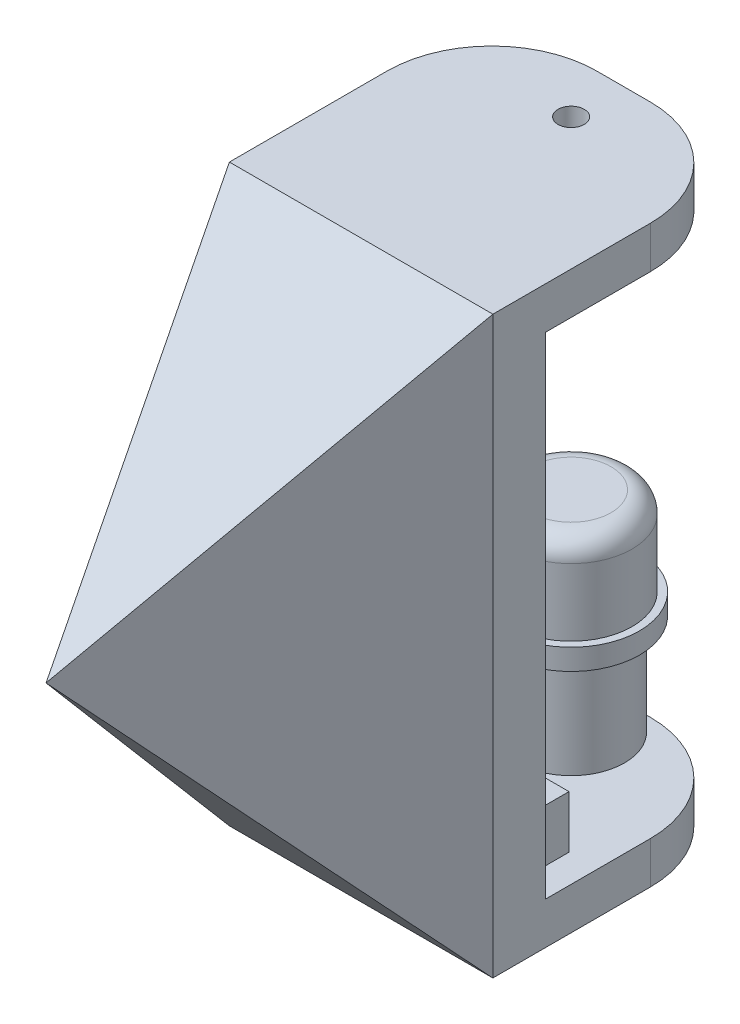
from build123d import *

# Parameters (mm, degrees)
SKETCH4_W                = 12.46
SKETCH4_H                = 17.25
BOSS_EXTRUDE3_DEPTH      = 6
SKETCH8_R                = 12.546781182
SKETCH8_R_2              = 11.15
BOSS_EXTRUDE6_DEPTH      = 7.3
BOSS_EXTRUDE6_DEPTH_BACK = 17.25
BOSS_EXTRUDE4_DEPTH      = 17.25
SKETCH6_R                = 0.5
CUT_EXTRUDE1_DEPTH       = 15
CHAMFER1_SIZE            = 0.5
CHAMFER1_SIZE2           = 0.866025404
SKETCH10_W               = 12.46
SKETCH10_H               = 23.7
CUT_EXTRUDE3_DEPTH       = 17.25
CUT_EXTRUDE4_REACH       = 38.097
SKETCH11_W               = 5
SKETCH11_H               = 3
BOSS_EXTRUDE7_DEPTH      = 7.3
BOSS_EXTRUDE9_DEPTH      = 10
SKETCH20_R               = 11.15
SKETCH20_R_2             = 7.15
BOSS_EXTRUDE11_DEPTH     = 7.3
SKETCH21_R               = 10.15
SKETCH21_R_2             = 7.15
CUT_EXTRUDE7_DEPTH       = 1.3
BOSS_EXTRUDE10_DEPTH     = 25.093562
SKETCH18_W               = 20
SKETCH18_H               = 12.438292938
CUT_EXTRUDE5_DEPTH       = 2
SKETCH19_R               = 1.25
CUT_EXTRUDE6_DEPTH       = 53.75
CUT_EXTRUDE6_DEPTH_BACK  = 3
FILLET1_R                = 10
SKETCH22_R               = 5.8
BOSS_EXTRUDE12_DEPTH     = 20
FILLET2_R                = 2
SKETCH23_R               = 5.930854157
SKETCH23_R_2             = 5.08
CUT_EXTRUDE8_DEPTH       = 11.6
SKETCH24_R               = 6.5
BOSS_EXTRUDE13_DEPTH     = 2
SKETCH25_R               = 1.25
BOSS_EXTRUDE14_DEPTH     = 2
SKETCH26_W               = 5
SKETCH26_H               = 3
BOSS_EXTRUDE15_DEPTH     = 5
SKETCH27_W               = 27.233314403
SKETCH27_H               = 38.605371191
CUT_EXTRUDE9_DEPTH       = 51.35
BOSS_EXTRUDE16_DEPTH     = 54.75
CUT_EXTRUDE10_DEPTH      = 13.546781182
CUT_EXTRUDE10_DEPTH_BACK = 13.546781182
CUT_EXTRUDE11_DEPTH      = 36


with BuildPart() as part:
    # Sketch4 → Boss-Extrude3 (new body)
    with BuildSketch(Plane.XY):
        with Locations((0, -1.35)):
            Rectangle(SKETCH4_W, SKETCH4_H)
    extrude(amount=BOSS_EXTRUDE3_DEPTH)



with BuildPart() as body_2:
    # Sketch8 → Boss-Extrude6 (new body, two sides)
    with BuildSketch(Plane(origin=(0, -9.975, 0), x_dir=(-1, 0, 0), z_dir=(0, -1, 0))) as boss_extrude6_sk:
        with Locations((0, -23.55)):
            Circle(SKETCH8_R)
        with Locations((0, -23.55)):
            Circle(SKETCH8_R_2, mode=Mode.SUBTRACT)
    extrude(amount=BOSS_EXTRUDE6_DEPTH)
    extrude(boss_extrude6_sk.sketch, amount=-BOSS_EXTRUDE6_DEPTH_BACK)


with BuildPart() as part_1:
    add(part.part)

    add(body_2.part)  # Boss-Extrude4 merges body 2
    # Sketch5 → Boss-Extrude4 (add)
    with BuildSketch(Plane(origin=(0, 7.275, 0), x_dir=(1, 0, 0), z_dir=(0, 1, 0))):
        with BuildLine():
            Line((12.546781182, -23.55), (12.546781182, 0))
            Line((12.546781182, 0), (6.23, 0))
            Line((6.23, 0), (6.23, -29.7))
            Line((6.23, -29.7), (-6.23, -29.7))
            Line((-6.23, -29.7), (-6.23, 0))
            Line((-6.23, 0), (-12.546781182, 0))
            Line((-12.546781182, 0), (-12.546781182, -23.55))
            ThreePointArc((-12.546781182, -23.55), (0, -36.096781182), (12.546781182, -23.55))
        make_face()
    extrude(amount=-BOSS_EXTRUDE4_DEPTH)

    # Sketch6 → Cut-Extrude1 (cut)
    with BuildSketch(Plane(origin=(0, 7.275, 0), x_dir=(1, 0, 0), z_dir=(0, 1, 0))):
        with Locations((0, -3.6)):
            Circle(SKETCH6_R)
        with Locations((0, -32.1)):
            Circle(SKETCH6_R)
    extrude(amount=-CUT_EXTRUDE1_DEPTH, mode=Mode.SUBTRACT)

    # Chamfer1
    chamfer1_edges = [part_1.edges().sort_by_distance(p)[0] for p in [
        (-0.5, 7.275, 3.6),
        (-0.5, 7.275, 32.1),
    ]]
    chamfer1_side = [part_1.faces().sort_by_distance(p)[0] for p in [
        (0, 7.275, 35.657160381),
    ]]
    chamfer(chamfer1_edges, length=CHAMFER1_SIZE, length2=CHAMFER1_SIZE2, reference=chamfer1_side[0])

    # Sketch10 → Cut-Extrude3 (cut)
    with BuildSketch(Plane(origin=(0, 7.275, 0), x_dir=(1, 0, 0), z_dir=(0, 1, 0))):
        with Locations((0, -17.85)):
            Rectangle(SKETCH10_W, SKETCH10_H)
    extrude(amount=-CUT_EXTRUDE3_DEPTH, mode=Mode.SUBTRACT)

    # Sketch11 → Cut-Extrude4 (cut, up to next)
    with BuildSketch(Plane.XY.offset(36.096781182), mode=Mode.PRIVATE) as cut_extrude4_sk1:
        with Locations((0, -8.475)):
            Rectangle(SKETCH11_W, SKETCH11_H)
    cut_extrude4_tool1 = extrude(cut_extrude4_sk1.sketch, amount=-CUT_EXTRUDE4_REACH, mode=Mode.PRIVATE) & part_1.part
    add(cut_extrude4_tool1.solids().sort_by_distance((0, -8.475, 36.096781))[0], mode=Mode.SUBTRACT)

    # Sketch13 → Boss-Extrude7 (add)
    with BuildSketch(Plane.XZ.offset(17.275)):
        with BuildLine():
            Line((-12.546781182, 23.55), (-12.546781182, 0))
            Line((-12.546781182, 0), (12.546781182, 0))
            Line((12.546781182, 0), (12.546781182, 23.55))
            ThreePointArc((12.546781182, 23.55), (0, 11.003218818), (-12.546781182, 23.55))
        make_face()
    extrude(amount=-BOSS_EXTRUDE7_DEPTH)

    # Sketch15 → Boss-Extrude9 (add)
    with BuildSketch(Plane(origin=(0, 7.275, 0), x_dir=(1, 0, 0), z_dir=(0, 1, 0))):
        with BuildLine():
            Line((-12.546781182, 0), (12.546781182, 0))
            Line((12.546781182, 0), (12.546781182, -23.55))
            ThreePointArc((12.546781182, -23.55), (0, -36.096781182), (-12.546781182, -23.55))
            Line((-12.546781182, -23.55), (-12.546781182, 0))
        make_face()
        with BuildLine():
            Line((-6.23, -0.8), (6.23, -0.8))
            Line((6.23, -0.8), (6.23, -33.5))
            ThreePointArc((6.23, -33.5), (5.937106781, -34.207106781), (5.23, -34.5))
            Line((5.23, -34.5), (-5.23, -34.5))
            ThreePointArc((-5.23, -34.5), (-5.937106781, -34.207106781), (-6.23, -33.5))
            Line((-6.23, -33.5), (-6.23, -0.8))
        make_face(mode=Mode.SUBTRACT)
    extrude(amount=BOSS_EXTRUDE9_DEPTH)

    # Sketch20 → Boss-Extrude11 (add)
    with BuildSketch(Plane.XZ.offset(17.275)):
        with Locations((0, 23.55)):
            Circle(SKETCH20_R)
        with Locations((0, 23.55)):
            Circle(SKETCH20_R_2, mode=Mode.SUBTRACT)
    extrude(amount=-BOSS_EXTRUDE11_DEPTH)

    # Sketch21 → Cut-Extrude7 (cut)
    with BuildSketch(Plane.XZ.offset(17.275)):
        with Locations((0, 23.55)):
            Circle(SKETCH21_R)
        with Locations((0, 23.55)):
            Circle(SKETCH21_R_2, mode=Mode.SUBTRACT)
    extrude(amount=-CUT_EXTRUDE7_DEPTH, mode=Mode.SUBTRACT)

    # Sketch17 → Boss-Extrude10 (add)
    with BuildSketch(Plane(origin=(12.546781182, 4.728218818, 0), x_dir=(0, 1, 0), z_dir=(-1, 0, 0))):
        Polygon((16.946781182, 25), (16.946781182, 0), (-37.803218818, 0), (-37.803218818, 25), (-33.803218818, 25), (-33.803218818, 5), (12.946781182, 5), (12.946781182, 25), align=None)
    extrude(amount=BOSS_EXTRUDE10_DEPTH)

    # Sketch18 → Cut-Extrude5 (cut)
    with BuildSketch(Plane(origin=(0, 17.675, 0), x_dir=(0, 0, 1), z_dir=(0, -1, 0))):
        with Locations((-15, 0)):
            Rectangle(SKETCH18_W, SKETCH18_H)
    extrude(amount=-CUT_EXTRUDE5_DEPTH, mode=Mode.SUBTRACT)

    # Sketch19 → Cut-Extrude6 (cut, two sides)
    with BuildSketch(Plane(origin=(0, 19.675, 0), x_dir=(0, 0, 1), z_dir=(0, -1, 0))) as cut_extrude6_sk:
        with Locations((-20, 0)):
            Circle(SKETCH19_R)
    extrude(amount=CUT_EXTRUDE6_DEPTH, mode=Mode.SUBTRACT)
    extrude(cut_extrude6_sk.sketch, amount=-CUT_EXTRUDE6_DEPTH_BACK, mode=Mode.SUBTRACT)

    # Fillet1
    fillet1_edges = [part_1.edges().sort_by_distance(p)[0] for p in [
        (-12.546780818, 19.675, -25),
        (12.546781182, 19.675, -25),
        (12.546781182, -31.075, -25),
        (-12.546780818, -31.075, -25),
    ]]
    fillet(fillet1_edges, radius=FILLET1_R)

    # Sketch22 → Boss-Extrude12 (add)
    with BuildSketch(Plane(origin=(0, -29.075, 0), x_dir=(0, 0, -1), z_dir=(0, 1, 0))):
        with Locations((20, 0)):
            Circle(SKETCH22_R)
    extrude(amount=BOSS_EXTRUDE12_DEPTH)

    # Fillet2
    fillet2_edges = [part_1.edges().sort_by_distance(p)[0] for p in [
        (0, -9.075, -14.2),
    ]]
    fillet(fillet2_edges, radius=FILLET2_R)

    # Sketch23 → Cut-Extrude8 (cut)
    with BuildSketch(Plane(origin=(0, -29.075, 0), x_dir=(0, 0, -1), z_dir=(0, 1, 0))):
        with Locations((20, 0)):
            Circle(SKETCH23_R)
        with Locations((20, 0)):
            Circle(SKETCH23_R_2, mode=Mode.SUBTRACT)
    extrude(amount=CUT_EXTRUDE8_DEPTH, mode=Mode.SUBTRACT)

    # Sketch24 → Boss-Extrude13 (add)
    with BuildSketch(Plane(origin=(0, -17.475, 0), x_dir=(0, 0, 1), z_dir=(0, -1, 0))):
        with Locations((-20, 0)):
            Circle(SKETCH24_R)
    extrude(amount=BOSS_EXTRUDE13_DEPTH)

    # Sketch25 → Boss-Extrude14 (add)
    with BuildSketch(Plane(origin=(0, -33.075, 0), x_dir=(0, 0, 1), z_dir=(0, -1, 0))):
        with Locations((-20, 0)):
            Circle(SKETCH25_R)
    extrude(amount=-BOSS_EXTRUDE14_DEPTH)

    # Sketch26 → Boss-Extrude15 (add)
    with BuildSketch(Plane(origin=(0, -29.075, 0), x_dir=(0, 0, -1), z_dir=(0, 1, 0))):
        with Locations((7.5, -8.296781182)):
            Rectangle(SKETCH26_W, SKETCH26_H)
        with Locations((7.5, -3.780781182)):
            Rectangle(SKETCH26_W, SKETCH26_H)
    extrude(amount=BOSS_EXTRUDE15_DEPTH)

    # Sketch27 → Cut-Extrude9 (cut, through all)
    with BuildSketch(Plane(origin=(0, 17.275, 0), x_dir=(1, 0, 0), z_dir=(0, 1, 0))):
        with Locations((1.06987602, -19.302685596)):
            Rectangle(SKETCH27_W, SKETCH27_H)
    extrude(amount=-CUT_EXTRUDE9_DEPTH, mode=Mode.SUBTRACT)

    # Sketch28 → Boss-Extrude16 (add)
    with BuildSketch(Plane(origin=(0, 21.675, 0), x_dir=(1, 0, 0), z_dir=(0, 1, 0))):
        Polygon((12.546781182, 0), (0, -30), (-12.546781182, 0), align=None)
    extrude(amount=-BOSS_EXTRUDE16_DEPTH)

    # Sketch29 → Cut-Extrude10 (cut, two sides)
    with BuildSketch(Plane(origin=(0, 0, 0), x_dir=(0, 0, -1), z_dir=(1, 0, 0))) as cut_extrude10_sk:
        Polygon((0, 21.675), (-30, 21.675), (-30, 0), align=None)
        Polygon((0, -33.075), (-30, -33.075), (-30, -0.02), align=None)
    extrude(amount=CUT_EXTRUDE10_DEPTH, mode=Mode.SUBTRACT)
    extrude(cut_extrude10_sk.sketch, amount=-CUT_EXTRUDE10_DEPTH_BACK, mode=Mode.SUBTRACT)

    # Sketch30 → Cut-Extrude11 (cut, through all)
    with BuildSketch(Plane(origin=(0, 0, -5), x_dir=(-1, 0, 0), z_dir=(0, 0, -1))):
        Polygon((12.546781182, 21.675), (0, 0), (12.546781182, -29.075), align=None)
    extrude(amount=-CUT_EXTRUDE11_DEPTH, mode=Mode.SUBTRACT)


solid = part_1.part
